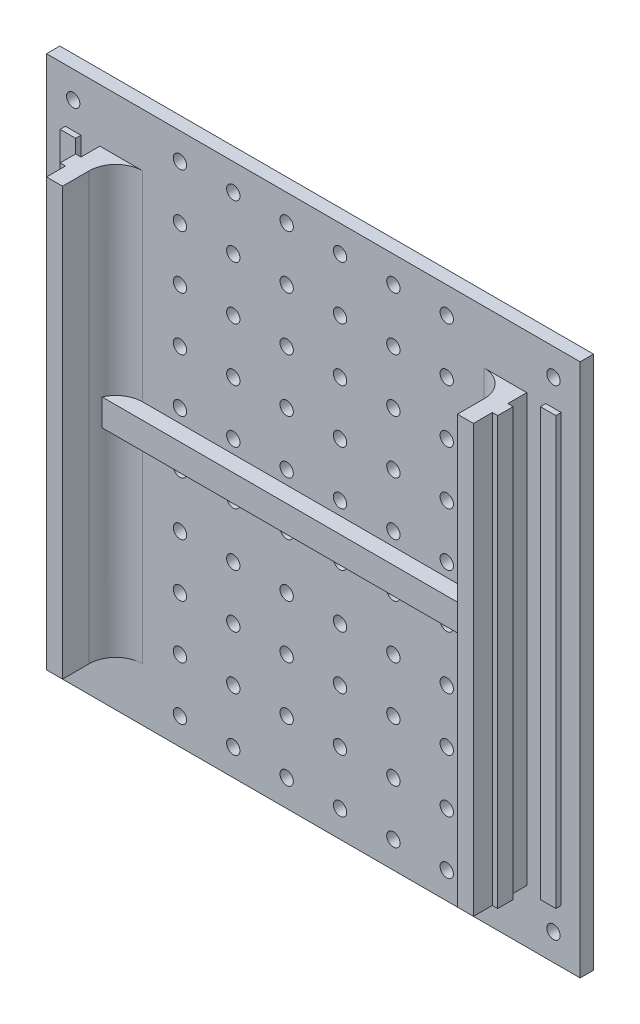
from build123d import *

# Parameters (mm, degrees)
SKETCH1_W            = 100
SKETCH1_H            = 100
MAIN_DEPTH           = 12.5
CUT_EXTRUDE1_DEPTH   = 51
SKETCH3_W            = 74
SKETCH3_H            = 10
CUT_EXTRUDE2_DEPTH   = 101
FILLET1_R            = 5
SKETCH9_W            = 80
SKETCH9_H            = 5
BOSS_EXTRUDE1_DEPTH  = 3
SKETCH4_R            = 1.25
FIXHOLE_DEPTH        = 3.5
LPATTERN1_COUNT      = 6
LPATTERN1_PITCH      = 10
LPATTERN1_COUNT_DIR2 = 10
LPATTERN1_PITCH_DIR2 = 10
SKETCH6_R            = 1.25
CENTRALHOLE_DEPTH    = 3.5
SKETCH7_W            = 100
SKETCH7_H            = 10
CUT_EXTRUDE3_DEPTH   = 10
SKETCH8_R            = 1.25
CUT_EXTRUDE4_DEPTH   = 3.5
LPATTERN2_COUNT      = 2
LPATTERN2_PITCH      = 90
LPATTERN2_COUNT_DIR2 = 2
LPATTERN2_PITCH_DIR2 = 90


with BuildPart() as part:
    # Sketch1 → Main (new body)
    with BuildSketch(Plane.XY):
        Rectangle(SKETCH1_W, SKETCH1_H)
    extrude(amount=MAIN_DEPTH)

    # Sketch2 → Cut-Extrude1 (cut, symmetric)
    with BuildSketch(Plane(origin=(0, 0, 0), x_dir=(1, 0, 0), z_dir=(0, 1, 0))):
        Polygon((-40, -8.95), (-40, -12.5), (-50, -12.5), (-50, -2.5), (-46.45, -2.5), (-46.45, -3.5), (-43.55, -3.5), (-43.55, -2.5), (-40, -2.5), (-40, -6.05), (-41, -6.05), (-41, -8.95), align=None)
    cut_extrude1 = extrude(amount=CUT_EXTRUDE1_DEPTH, both=True, mode=Mode.SUBTRACT)

    # Mirror1: Cut-Extrude1 across plane
    add(cut_extrude1.mirror(Plane(origin=(0, 0, 0), x_dir=(0, 0, 1), z_dir=(1, 0, 0))), mode=Mode.SUBTRACT)

    # Sketch3 → Cut-Extrude2 (cut, through all)
    with BuildSketch(Plane(origin=(0, 50, 0), x_dir=(1, 0, 0), z_dir=(0, 1, 0))):
        with Locations((0, -7.5)):
            Rectangle(SKETCH3_W, SKETCH3_H)
    extrude(amount=-CUT_EXTRUDE2_DEPTH, mode=Mode.SUBTRACT)

    # Fillet1
    fillet1_edges = [part.edges().sort_by_distance(p)[0] for p in [
        (-37, 0, 2.5),
        (37, 0, 2.5),
    ]]
    fillet(fillet1_edges, radius=FILLET1_R)

    # Sketch9 → Boss-Extrude1 (add)
    with BuildSketch(Plane.XY.offset(2.5)):
        Rectangle(SKETCH9_W, SKETCH9_H)
    extrude(amount=BOSS_EXTRUDE1_DEPTH)

    # Sketch4 → FixHole (cut, through all)
    with BuildSketch(Plane.XY.offset(2.5)):
        with Locations((25, -45)):
            Circle(SKETCH4_R)
    fixhole = extrude(amount=-FIXHOLE_DEPTH, mode=Mode.SUBTRACT)

    # LPattern1: FixHole 6 × 10
    with Locations(*[(-i * LPATTERN1_PITCH, j * LPATTERN1_PITCH_DIR2, 0) for i in range(LPATTERN1_COUNT) for j in range(LPATTERN1_COUNT_DIR2) if (i, j) != (0, 0)]):
        add(fixhole, mode=Mode.SUBTRACT)

    # Sketch6 → CentralHole (cut, through all)
    with BuildSketch(Plane.XY.offset(2.5)):
        Circle(SKETCH6_R)
    extrude(amount=-CENTRALHOLE_DEPTH, mode=Mode.SUBTRACT)

    # Sketch7 → Cut-Extrude3 (cut)
    with BuildSketch(Plane(origin=(0, 0, 12.5), x_dir=(-1, 0, 0), z_dir=(0, 0, -1))):
        with Locations((0, -45)):
            Rectangle(SKETCH7_W, SKETCH7_H)
        with Locations((0, 45)):
            Rectangle(SKETCH7_W, SKETCH7_H)
    extrude(amount=CUT_EXTRUDE3_DEPTH, mode=Mode.SUBTRACT)

    # Sketch8 → Cut-Extrude4 (cut, through all)
    with BuildSketch(Plane.XY.offset(2.5)):
        with Locations((-45, 45)):
            Circle(SKETCH8_R)
    cut_extrude4 = extrude(amount=-CUT_EXTRUDE4_DEPTH, mode=Mode.SUBTRACT)

    # LPattern2: Cut-Extrude4 2 × 2
    with Locations(*[(i * LPATTERN2_PITCH, -j * LPATTERN2_PITCH_DIR2, 0) for i in range(LPATTERN2_COUNT) for j in range(LPATTERN2_COUNT_DIR2) if (i, j) != (0, 0)]):
        add(cut_extrude4, mode=Mode.SUBTRACT)


solid = part.part
